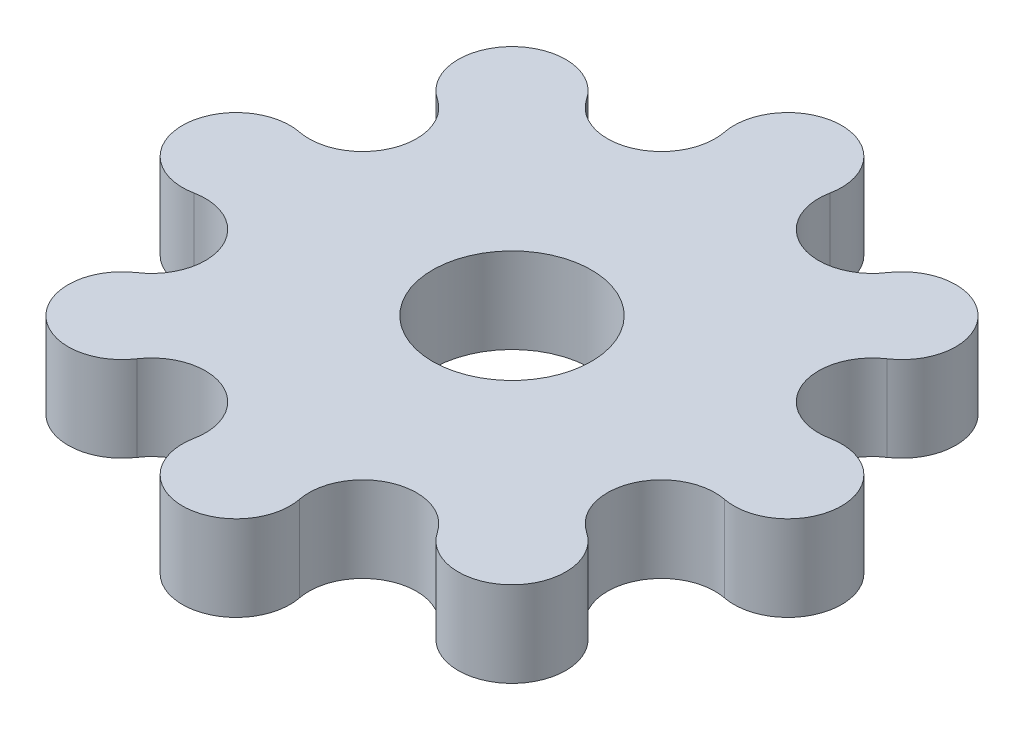
from build123d import *

# Parameters (mm, degrees)
SKETCH1_R           = 4
BOSS_EXTRUDE1_DEPTH = 3.175
SKETCH2_R           = 4
SKETCH2_R_2         = 2.95
BOSS_EXTRUDE2_DEPTH = 3.175


with BuildPart() as part:
    # Sketch1 → Boss-Extrude1 (new body)
    with BuildSketch(Plane(origin=(0, 0, 0), x_dir=(1, 0, 0), z_dir=(0, 1, 0))):
        with BuildLine():
            ThreePointArc((1.961570561, 9.861481147), (0, 12.251661791), (-1.961570561, 9.861481147))
            ThreePointArc((-1.961570561, 9.861481147), (-3.157774257, 7.623541438), (-5.586080346, 8.360160037))
            ThreePointArc((-5.586080346, 8.360160037), (-8.663233133, 8.663233133), (-8.360160037, 5.586080346))
            ThreePointArc((-8.360160037, 5.586080346), (-7.623541438, 3.157774257), (-9.861481147, 1.961570561))
            ThreePointArc((-9.861481147, 1.961570561), (-12.251661791, 0), (-9.861481147, -1.961570561))
            ThreePointArc((-9.861481147, -1.961570561), (-7.623541438, -3.157774257), (-8.360160037, -5.586080346))
            ThreePointArc((-8.360160037, -5.586080346), (-8.663233133, -8.663233133), (-5.586080346, -8.360160037))
            ThreePointArc((-5.586080346, -8.360160037), (-3.157774257, -7.623541438), (-1.961570561, -9.861481147))
            ThreePointArc((-1.961570561, -9.861481147), (0, -12.251661791), (1.961570561, -9.861481147))
            ThreePointArc((1.961570561, -9.861481147), (3.157774257, -7.623541438), (5.586080346, -8.360160037))
            ThreePointArc((5.586080346, -8.360160037), (8.663233133, -8.663233133), (8.360160037, -5.586080346))
            ThreePointArc((8.360160037, -5.586080346), (7.623541438, -3.157774257), (9.861481147, -1.961570561))
            ThreePointArc((9.861481147, -1.961570561), (12.251661791, 0), (9.861481147, 1.961570561))
            ThreePointArc((9.861481147, 1.961570561), (7.623541438, 3.157774257), (8.360160037, 5.586080346))
            ThreePointArc((8.360160037, 5.586080346), (8.663233133, 8.663233133), (5.586080346, 8.360160037))
            ThreePointArc((5.586080346, 8.360160037), (3.157774257, 7.623541438), (1.961570561, 9.861481147))
        make_face()
        Circle(SKETCH1_R, mode=Mode.SUBTRACT)
    extrude(amount=BOSS_EXTRUDE1_DEPTH)

    # Sketch2 → Boss-Extrude2 (add)
    with BuildSketch(Plane(origin=(0, 3.175, 0), x_dir=(1, 0, 0), z_dir=(0, 1, 0))):
        Circle(SKETCH2_R)
        Circle(SKETCH2_R_2, mode=Mode.SUBTRACT)
    extrude(amount=-BOSS_EXTRUDE2_DEPTH)


solid = part.part
